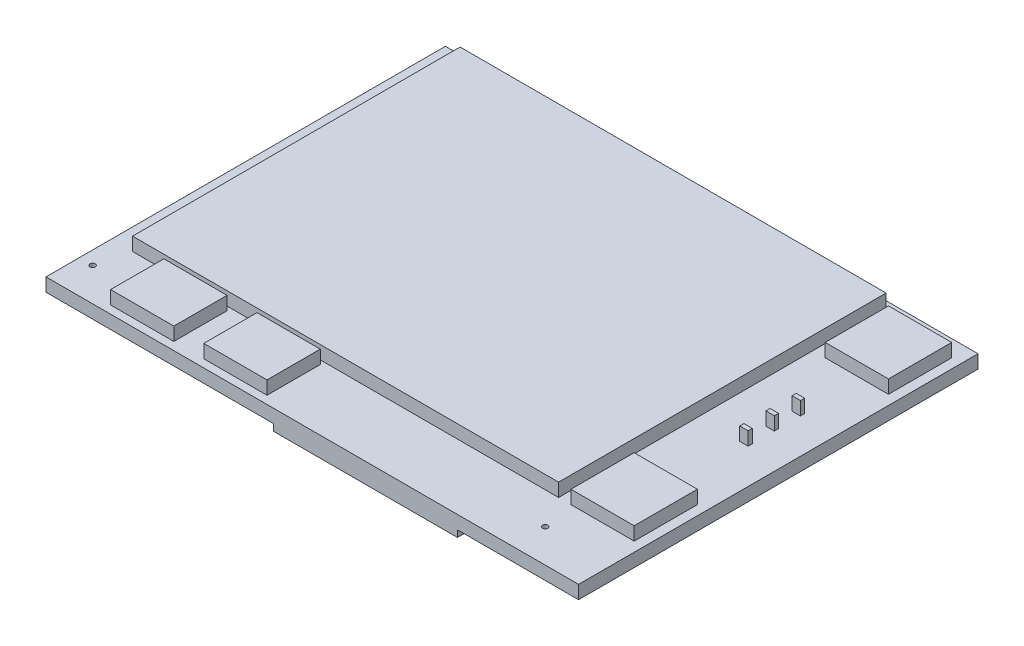
from build123d import *

# Parameters (mm, degrees)
SKETCH1_W           = 101.6
SKETCH1_H           = 76.2
BOSS_EXTRUDE1_DEPTH = 2.54
SKETCH3_W           = 35.052
SKETCH3_H           = 56.134
SKETCH3_W_2         = 9.4
SKETCH3_H_2         = 11
BOSS_EXTRUDE4_DEPTH = 1.27
SKETCH2_W           = 1.6
SKETCH2_H           = 0.8
SKETCH2_W_2         = 81.28
SKETCH2_H_2         = 62.484
SKETCH2_W_3         = 12.065
SKETCH2_H_3         = 12.065
SKETCH2_H_4         = 10.16
BOSS_EXTRUDE5_DEPTH = 2.54
SKETCH2_3_R         = 0.508
CUT_EXTRUDE1_DEPTH  = 64.614197315


with BuildPart() as part:
    # Sketch1 → Boss-Extrude1 (new body)
    with BuildSketch(Plane(origin=(0, 0, 0), x_dir=(1, 0, 0), z_dir=(0, 1, 0))):
        Rectangle(SKETCH1_W, SKETCH1_H)
    extrude(amount=BOSS_EXTRUDE1_DEPTH)

    # Sketch3 → Boss-Extrude4 (add)
    with BuildSketch(Plane.XZ):
        with Locations((10.16, 10.033)):
            Rectangle(SKETCH3_W, SKETCH3_H)
        with Locations((-22.478, -32.6)):
            Rectangle(SKETCH3_W_2, SKETCH3_H_2)
    extrude(amount=BOSS_EXTRUDE4_DEPTH)

    # Sketch2 → Boss-Extrude5 (add)
    with BuildSketch(Plane(origin=(0, 2.54, 0), x_dir=(1, 0, 0), z_dir=(0, 1, 0))):
        with Locations((43.345, 6.293)):
            Rectangle(SKETCH2_W, SKETCH2_H)
        with Locations((-6.096, 5.588)):
            Rectangle(SKETCH2_W_2, SKETCH2_H_2)
        with Locations((42.926, 28.8925)):
            Rectangle(SKETCH2_W_3, SKETCH2_H_3)
        with Locations((42.926, -19.6215)):
            Rectangle(SKETCH2_W_3, SKETCH2_H_3)
        with Locations((43.345, 1.302)):
            Rectangle(SKETCH2_W, SKETCH2_H)
        with Locations((43.345, 11.284)):
            Rectangle(SKETCH2_W, SKETCH2_H)
        with Locations((-33.9725, -31.496)):
            Rectangle(SKETCH2_W_3, SKETCH2_H_4)
        with Locations((-16.1925, -31.496)):
            Rectangle(SKETCH2_W_3, SKETCH2_H_4)
    extrude(amount=BOSS_EXTRUDE5_DEPTH)

    # Sketch2_3 → Cut-Extrude1 (cut, through all)
    with BuildSketch(Plane(origin=(0, 2.54, 0), x_dir=(1, 0, 0), z_dir=(0, 1, 0))):
        with Locations((-48.26, -31.75)):
            Circle(SKETCH2_3_R)
        with Locations((38.1, 36.83)):
            Circle(SKETCH2_3_R)
        with Locations((38.1, -31.75)):
            Circle(SKETCH2_3_R)
    extrude(amount=-CUT_EXTRUDE1_DEPTH, mode=Mode.SUBTRACT)


solid = part.part
